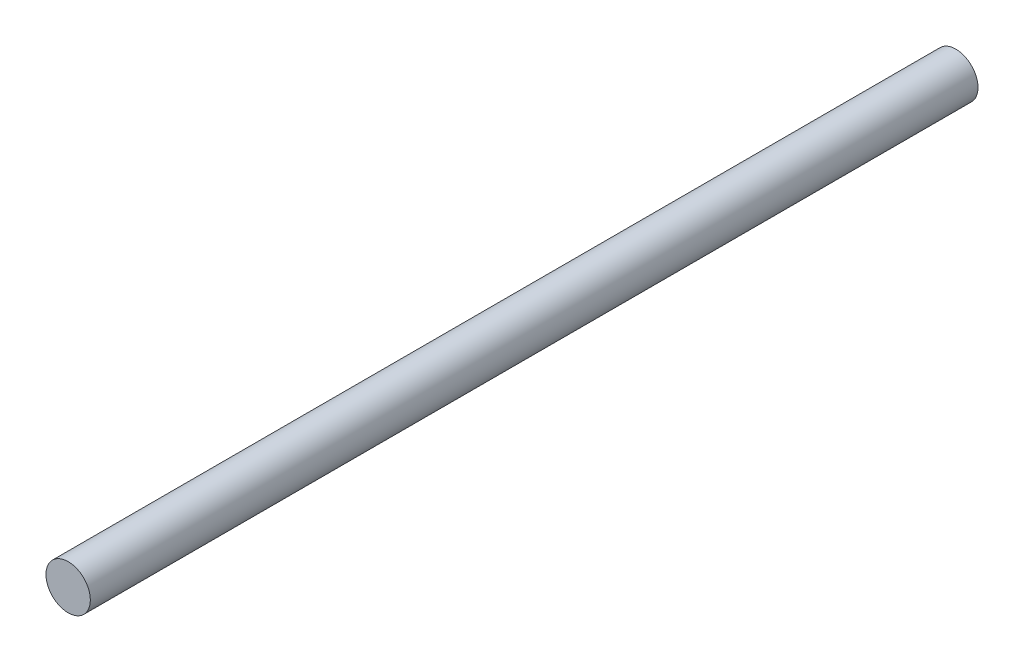
from build123d import *

# Parameters (mm, degrees)
SKETCH_1_R      = 0.25
EXTRUDE_1_DEPTH = 10


with BuildPart() as part:
    # ｽｹｯﾁ1 → ﾎﾞｽ - 押し出し1 (new body)
    with BuildSketch(Plane.XY):
        Circle(SKETCH_1_R)
    extrude(amount=EXTRUDE_1_DEPTH)


solid = part.part
